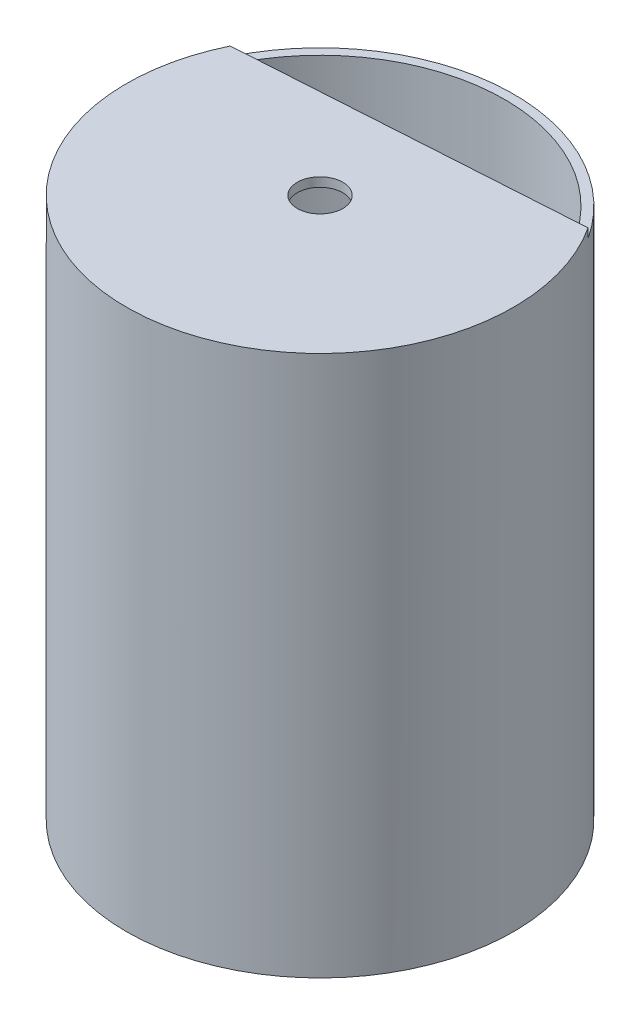
from build123d import *

# Parameters (mm, degrees)
SKETCH1_R           = 10.795
SKETCH1_R_2         = 10.287
BOSS_EXTRUDE1_DEPTH = 29.6418
BOSS_EXTRUDE3_DEPTH = 0.508
SKETCH3_R           = 1.27
CUT_EXTRUDE1_DEPTH  = 31.1498
BOSS_EXTRUDE4_REACH = 32.15


with BuildPart() as part:
    # Sketch1 → Boss-Extrude1 (new body)
    with BuildSketch(Plane(origin=(0, 0, 0), x_dir=(1, 0, 0), z_dir=(0, 1, 0))):
        Circle(SKETCH1_R)
        Circle(SKETCH1_R_2, mode=Mode.SUBTRACT)
    extrude(amount=BOSS_EXTRUDE1_DEPTH)

    # Sketch2 → Boss-Extrude3 (add)
    with BuildSketch(Plane(origin=(0, 29.6418, 0), x_dir=(1, 0, 0), z_dir=(0, 1, 0))):
        with BuildLine():
            Line((8.451883262, 5.864131507), (-9.126833577, 4.745869558))
            ThreePointArc((-9.126833577, 4.745869558), (-2.442809038, -9.992750022), (10.287, 0))
            ThreePointArc((10.287, 0), (9.81750712, 3.072283018), (8.451883262, 5.864131507))
        make_face()
        with BuildLine():
            Line((-9.126833577, 4.745869558), (-9.714005015, 4.708516918))
            ThreePointArc((-9.714005015, 4.708516918), (-2.415506247, -10.521281033), (10.795, 0))
            ThreePointArc((10.795, 0), (10.346705284, 3.078589735), (9.0390547, 5.901484146))
            Line((9.0390547, 5.901484146), (8.451883262, 5.864131507))
            ThreePointArc((8.451883262, 5.864131507), (9.81750712, 3.072283018), (10.287, 0))
            ThreePointArc((10.287, 0), (-2.442809038, -9.992750022), (-9.126833577, 4.745869558))
        make_face()
    extrude(amount=BOSS_EXTRUDE3_DEPTH)

    # Sketch3 → Cut-Extrude1 (cut, through all)
    with BuildSketch(Plane(origin=(0, 30.1498, 0), x_dir=(1, 0, 0), z_dir=(0, 1, 0))):
        Circle(SKETCH3_R)
    extrude(amount=-CUT_EXTRUDE1_DEPTH, mode=Mode.SUBTRACT)

    # Sketch6 → Boss-Extrude4 (add, up to next)
    with BuildSketch(Plane.XZ, mode=Mode.PRIVATE) as boss_extrude4_sk1:
        with BuildLine():
            Line((-3.869377765, 7.761308892), (4.821670905, 7.208431847))
            Line((4.821670905, 7.208431847), (7.502708149, 7.037878901))
            ThreePointArc((7.502708149, 7.037878901), (0.653082635, 10.266248198), (-6.550415009, 7.931861837))
            Line((-6.550415009, 7.931861837), (-3.869377765, 7.761308892))
        make_face()
    boss_extrude4_tool1 = extrude(boss_extrude4_sk1.sketch, amount=-BOSS_EXTRUDE4_REACH, mode=Mode.PRIVATE) - part.part
    add(boss_extrude4_tool1.solids().sort_by_distance((0.547813, 0, 8.611444))[0])


solid = part.part
